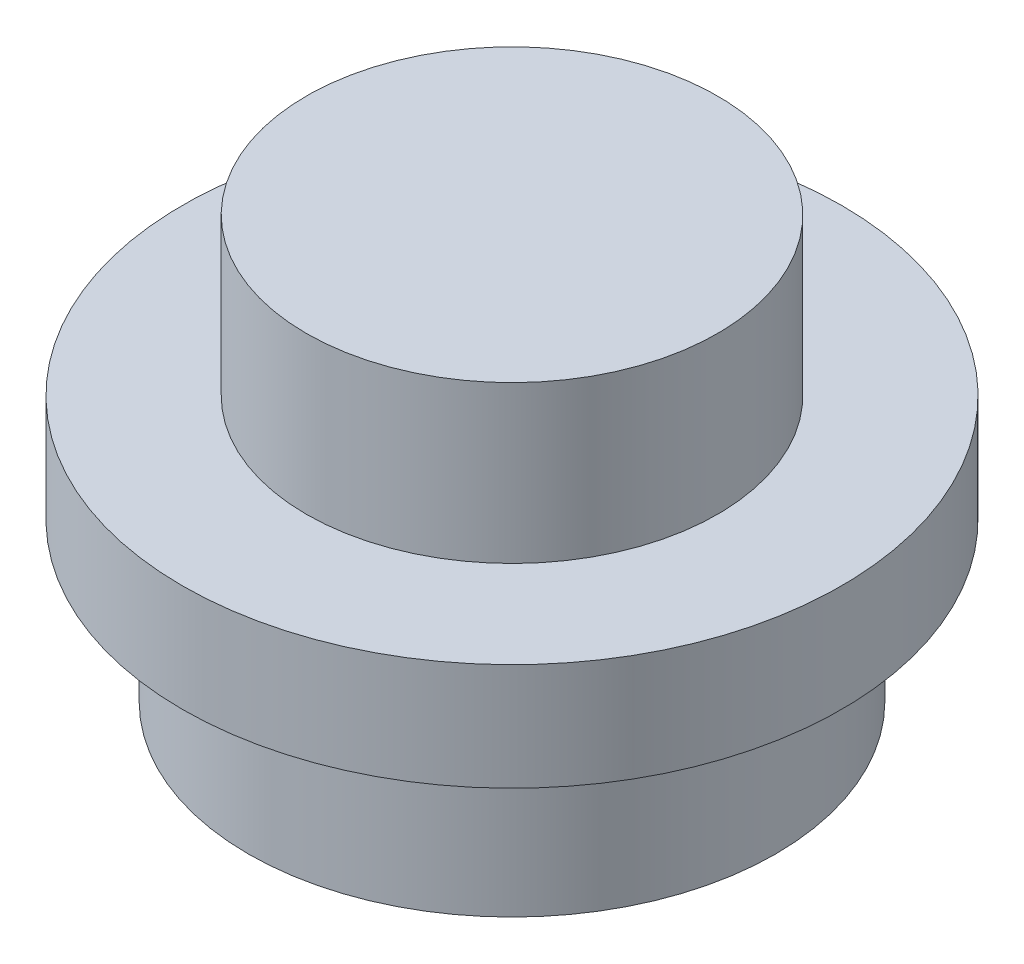
from build123d import *


with BuildPart() as part:
    # Sketch1 → Revolve1 (revolve)
    with BuildSketch(Plane.XY):
        Polygon((-0.455886696, 2.159), (-2.837136696, 2.159), (-2.837136696, 0), (-3.630886696, 0), (-3.630886696, 1.905), (-4.424636696, 1.905), (-4.424636696, 3.193744783), (-2.932386696, 3.193744783), (-2.932386696, 5.08), (-0.455886696, 5.08), align=None)
    revolve(axis=Axis((-0.455886696, 5.08, 0), (0, -1, 0)))


solid = part.part
